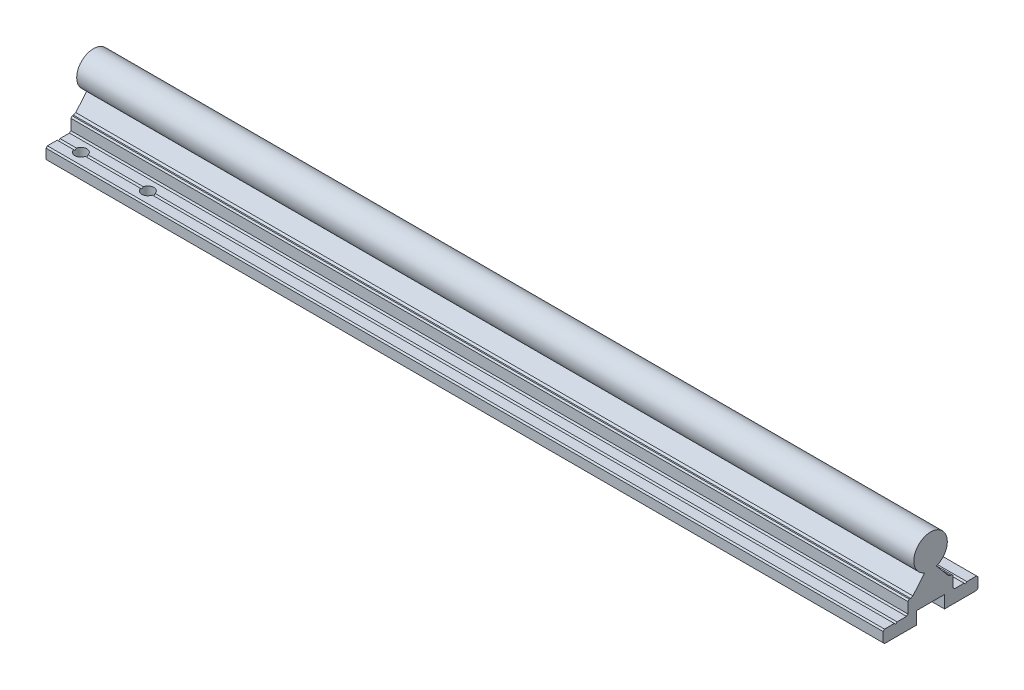
from build123d import *

# Parameters (mm, degrees)
EXTRUDE1_DEPTH     = 300
SKETCH2_R          = 2.15
CUT_EXTRUDE1_DEPTH = 10


with BuildPart() as part:
    # Sketch1 → Extrude1 (new body)
    with BuildSketch(Plane(origin=(0, 0, 0), x_dir=(0, 0, -1), z_dir=(1, 0, 0))):
        with BuildLine():
            Line((-2.104066935, 2.654149118), (-6.339664187, -2.393639124))
            Line((-6.339664187, -2.393639124), (-7.161057992, -2.776661346))
            Line((-7.161057992, -2.776661346), (-7.600420417, -2.776661346))
            Line((-7.600420417, -2.776661346), (-8.100420417, -3.276661346))
            Line((-8.100420417, -3.276661346), (-8.100420417, -7.1268739))
            Line((-8.100420417, -7.1268739), (-8.600420417, -7.6268739))
            Line((-8.600420417, -7.6268739), (-12, -7.6268739))
            Line((-12, -7.6268739), (-12.5, -8.1268739))
            Line((-12.5, -8.1268739), (-13, -7.6268739))
            Line((-13, -7.6268739), (-16.5, -7.6268739))
            Line((-16.5, -7.6268739), (-17, -8.1268739))
            Line((-17, -8.1268739), (-17, -11.6268739))
            Line((-17, -11.6268739), (-16.5, -12.1268739))
            Line((-16.5, -12.1268739), (-5, -12.1268739))
            Line((-5, -12.1268739), (-5, -7.6268739))
            Line((-5, -7.6268739), (5, -7.6268739))
            Line((5, -7.6268739), (5, -12.1268739))
            Line((5, -12.1268739), (16.5, -12.1268739))
            Line((16.5, -12.1268739), (17, -11.6268739))
            Line((17, -11.6268739), (17, -8.1268739))
            Line((17, -8.1268739), (16.5, -7.6268739))
            Line((16.5, -7.6268739), (13, -7.6268739))
            Line((13, -7.6268739), (12.5, -8.1268739))
            Line((12.5, -8.1268739), (12, -7.6268739))
            Line((12, -7.6268739), (8.600420417, -7.6268739))
            Line((8.600420417, -7.6268739), (8.100420417, -7.1268739))
            Line((8.100420417, -7.1268739), (8.100420417, -3.276661346))
            Line((8.100420417, -3.276661346), (7.600420417, -2.776661346))
            Line((7.600420417, -2.776661346), (7.161057992, -2.776661346))
            Line((7.161057992, -2.776661346), (6.339664187, -2.393639124))
            Line((6.339664187, -2.393639124), (2.104066935, 2.654149118))
            ThreePointArc((2.104066935, 2.654149118), (0, 14.2731261), (-2.104066935, 2.654149118))
        make_face()
    extrude(amount=EXTRUDE1_DEPTH)

    # Sketch2 → Cut-Extrude1 (cut)
    with BuildSketch(Plane.XZ.offset(12.1268739)):
        with Locations((32, -12.5)):
            Circle(SKETCH2_R)
        with Locations((8, -12.5)):
            Circle(SKETCH2_R)
        with Locations((32, 12.5)):
            Circle(SKETCH2_R)
        with Locations((8, 12.5)):
            Circle(SKETCH2_R)
    extrude(amount=-CUT_EXTRUDE1_DEPTH, mode=Mode.SUBTRACT)


solid = part.part
